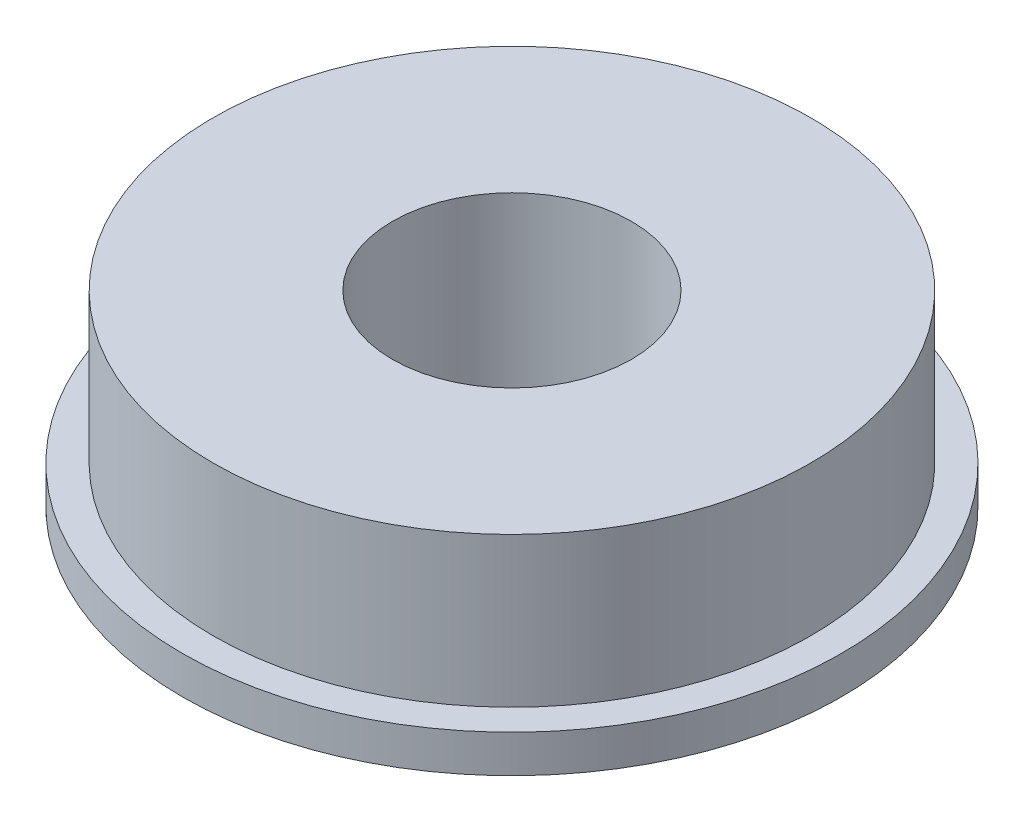
from build123d import *

# Parameters (mm, degrees)
SKETCH1_R           = 8.75
BOSS_EXTRUDE1_DEPTH = 1
SKETCH2_R           = 7.9375
BOSS_EXTRUDE2_DEPTH = 3.973
SKETCH3_R           = 3.175
CUT_EXTRUDE1_DEPTH  = 5.973


with BuildPart() as part:
    # Sketch1 → Boss-Extrude1 (new body)
    with BuildSketch(Plane(origin=(0, 0, 0), x_dir=(1, 0, 0), z_dir=(0, 1, 0))):
        Circle(SKETCH1_R)
    extrude(amount=BOSS_EXTRUDE1_DEPTH)

    # Sketch2 → Boss-Extrude2 (add)
    with BuildSketch(Plane(origin=(0, 1, 0), x_dir=(1, 0, 0), z_dir=(0, 1, 0))):
        Circle(SKETCH2_R)
    extrude(amount=BOSS_EXTRUDE2_DEPTH)

    # Sketch3 → Cut-Extrude1 (cut, through all)
    with BuildSketch(Plane(origin=(0, 4.973, 0), x_dir=(1, 0, 0), z_dir=(0, 1, 0))):
        Circle(SKETCH3_R)
    extrude(amount=-CUT_EXTRUDE1_DEPTH, mode=Mode.SUBTRACT)


solid = part.part
